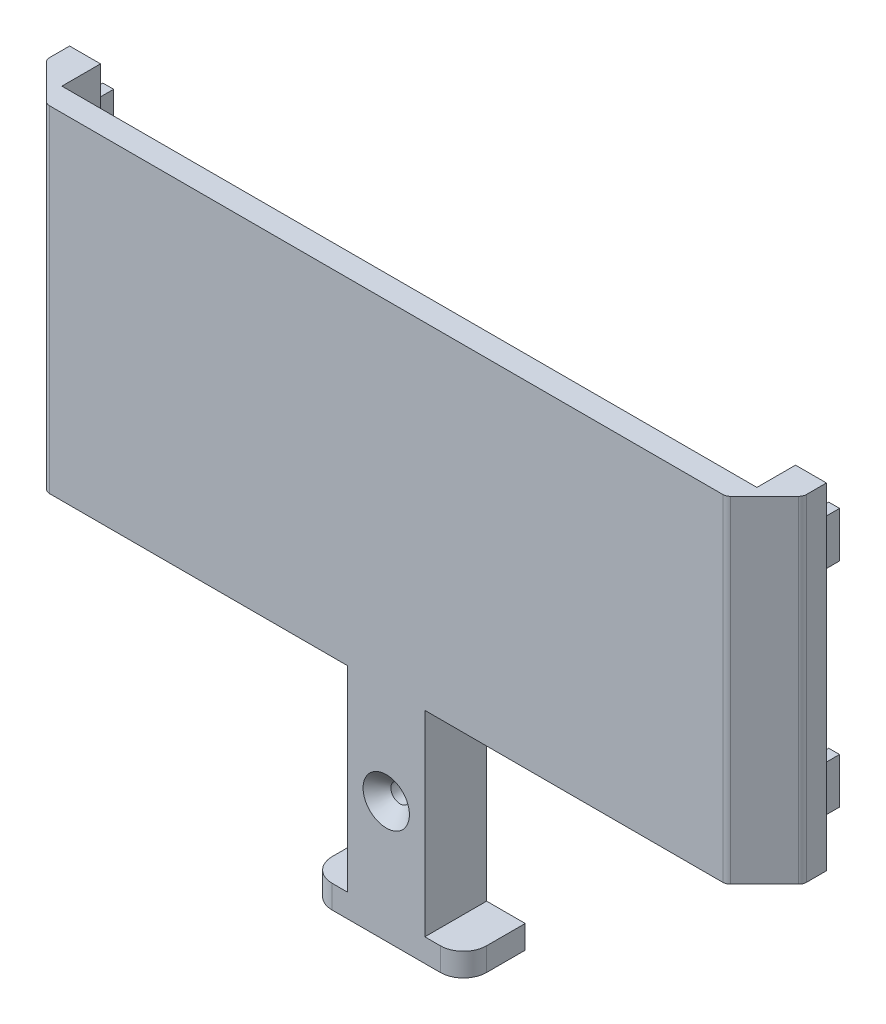
from build123d import *

# Parameters (mm, degrees)
SKETCH2_W                                       = 96
SKETCH2_H                                       = 38.5
BOSS_EXTRUDE1_DEPTH                             = 3
BOSS_EXTRUDE2_DEPTH                             = 45
BOSS_EXTRUDE2_DEPTH_BACK                        = 20
BOSS_EXTRUDE3_DEPTH                             = 20
BOSS_EXTRUDE3_DEPTH_BACK                        = 45
SKETCH5_W                                       = 8
SKETCH5_H                                       = 5
BOSS_EXTRUDE4_DEPTH                             = 96
SKETCH6_W                                       = 3
SKETCH6_H                                       = 5
BOSS_EXTRUDE5_DEPTH                             = 38.5
SKETCH7_R                                       = 7.5
SKETCH7_R_2                                     = 3.5
CUT_EXTRUDE2_DEPTH                              = 2
MOVE_FACE1_BY                                   = 1
MOVE_FACE2_BY                                   = 1
SKETCH8_W                                       = 1.4
SKETCH8_H                                       = 5.9
BOSS_EXTRUDE6_DEPTH                             = 3
SKETCH9_W                                       = 10
SKETCH9_H                                       = 8
BOSS_EXTRUDE7_DEPTH                             = 25.4
SKETCH11_W                                      = 8
SKETCH11_H                                      = 3
BOSS_EXTRUDE8_DEPTH                             = 10
CHAMFER1_SIZE                                   = 5
FILLET1_R                                       = 1
FILLET3_R                                       = 3
MOVE_FACE3_BY                                   = 2
CSK_FOR_M2_FLAT_HEAD_MACHINE_SCREW1_D           = 2.4
CSK_FOR_M2_FLAT_HEAD_MACHINE_SCREW1_CSINK_D     = 6
CSK_FOR_M2_FLAT_HEAD_MACHINE_SCREW1_CSINK_ANGLE = 90


with BuildPart() as part:
    # Sketch2 → Boss-Extrude1 (new body)
    with BuildSketch(Plane.XY):
        Rectangle(SKETCH2_W, SKETCH2_H)
    extrude(amount=BOSS_EXTRUDE1_DEPTH)

    # Sketch3 → Boss-Extrude2 (add, two sides: drawn at the far end of the back side and taken through both)
    with BuildSketch(Plane(origin=(0, 0, 0), x_dir=(0, 0, -1), z_dir=(1, 0, 0)).offset(-BOSS_EXTRUDE2_DEPTH_BACK)):
        with BuildLine():
            Line((0, -15.25), (1.75, -15.25))
            ThreePointArc((1.75, -15.25), (2.5, -14.5), (1.75, -13.75))
            Line((1.75, -13.75), (0, -13.75))
            Line((0, -13.75), (0, -15.25))
        make_face()
    extrude(amount=BOSS_EXTRUDE2_DEPTH + BOSS_EXTRUDE2_DEPTH_BACK)

    # Sketch3_3 → Boss-Extrude3 (add, two sides: drawn at the far end of the back side and taken through both)
    with BuildSketch(Plane(origin=(0, 0, 0), x_dir=(0, 0, -1), z_dir=(1, 0, 0)).offset(-BOSS_EXTRUDE3_DEPTH_BACK)):
        with BuildLine():
            Line((0, 13.75), (0, 15.25))
            Line((0, 15.25), (1.75, 15.25))
            ThreePointArc((1.75, 15.25), (2.5, 14.5), (1.75, 13.75))
            Line((1.75, 13.75), (0, 13.75))
        make_face()
    extrude(amount=BOSS_EXTRUDE3_DEPTH + BOSS_EXTRUDE3_DEPTH_BACK)

    # Cut-Extrude1 cone 1 section (through the dimple's axis) → Cut-Extrude1 (revolve, cut)
    with BuildSketch(Plane.YZ):
        Polygon((0, 0), (1.375, 0), (0, 1.375), align=None)
    revolve(axis=Axis((0, 0, 0), (0, 0, 1)), mode=Mode.SUBTRACT)

    # Sketch5 → Boss-Extrude4 (add, through all)
    with BuildSketch(Plane.ZY.offset(48)):
        with Locations((-1, -21.75)):
            Rectangle(SKETCH5_W, SKETCH5_H)
    extrude(amount=-BOSS_EXTRUDE4_DEPTH)

    # Sketch6 → Boss-Extrude5 (add, through all)
    with BuildSketch(Plane(origin=(0, -19.25, 0), x_dir=(1, 0, 0), z_dir=(0, 1, 0))):
        with Locations((-46.5, 2.5)):
            Rectangle(SKETCH6_W, SKETCH6_H)
        with Locations((46.5, 2.5)):
            Rectangle(SKETCH6_W, SKETCH6_H)
    extrude(amount=BOSS_EXTRUDE5_DEPTH)

    # Sketch7 → Cut-Extrude2 (cut)
    with BuildSketch(Plane(origin=(0, 0, 0), x_dir=(-1, 0, 0), z_dir=(0, 0, -1))):
        Circle(SKETCH7_R)
        Circle(SKETCH7_R_2, mode=Mode.SUBTRACT)
    extrude(amount=-CUT_EXTRUDE2_DEPTH, mode=Mode.SUBTRACT)

    # Move Face1: a face moved outward by 1.0
    extrude(part.faces().sort_by_distance((-48, -2.5, -1))[0], amount=MOVE_FACE1_BY, dir=(-1, 0, 0))

    # Move Face2: a face moved outward by 1.0
    extrude(part.faces().sort_by_distance((48, -2.5, -1))[0], amount=MOVE_FACE2_BY, dir=(1, 0, 0))

    # Sketch8 → Boss-Extrude6 (add)
    with BuildSketch(Plane(origin=(0, 0, -5), x_dir=(-1, 0, 0), z_dir=(0, 0, -1))):
        with Locations((-47, 11.3)):
            Rectangle(SKETCH8_W, SKETCH8_H)
        with Locations((-47, -16.3)):
            Rectangle(SKETCH8_W, SKETCH8_H)
        with Locations((47, 11.3)):
            Rectangle(SKETCH8_W, SKETCH8_H)
        with Locations((47, -16.3)):
            Rectangle(SKETCH8_W, SKETCH8_H)
    extrude(amount=BOSS_EXTRUDE6_DEPTH)

    # Sketch9 → Boss-Extrude7 (add)
    with BuildSketch(Plane.XZ.offset(24.25)):
        with Locations((0, -1)):
            Rectangle(SKETCH9_W, SKETCH9_H)
    extrude(amount=BOSS_EXTRUDE7_DEPTH)

    # Sketch11 → Boss-Extrude8 (add, symmetric)
    with BuildSketch(Plane(origin=(0, 0, 0), x_dir=(0, 0, -1), z_dir=(1, 0, 0))):
        with Locations((1, -51.15)):
            Rectangle(SKETCH11_W, SKETCH11_H)
    extrude(amount=BOSS_EXTRUDE8_DEPTH, both=True)

    # Chamfer1
    chamfer1_edges = [part.edges().sort_by_distance(p)[0] for p in [
        (49, -2.5, 3),
        (-49, -2.5, 3),
    ]]
    chamfer(chamfer1_edges, length=CHAMFER1_SIZE)

    # Fillet1
    fillet1_edges = [part.edges().sort_by_distance(p)[0] for p in [
        (44, -2.5, 3),
        (-44, -2.5, 3),
        (-49, -2.5, -2),
        (49, -2.5, -2),
    ]]
    fillet(fillet1_edges, radius=FILLET1_R)

    # Fillet3
    fillet3_edges = [part.edges().sort_by_distance(p)[0] for p in [
        (-10, -51.15, 3),
        (10, -51.15, 3),
    ]]
    fillet(fillet3_edges, radius=FILLET3_R)

    # Move Face3: a face moved inward by 2.0
    extrude(part.faces().sort_by_distance((0, -19.25, -2.5))[0], amount=MOVE_FACE3_BY, dir=(0, -1, 0), mode=Mode.SUBTRACT)

    # CSK for M2 Flat Head Machine Screw1 (through all)
    with Locations(Plane.XY.offset(3)):
        with Locations((0, -36.95)):
            CounterSinkHole(CSK_FOR_M2_FLAT_HEAD_MACHINE_SCREW1_D / 2, CSK_FOR_M2_FLAT_HEAD_MACHINE_SCREW1_CSINK_D / 2, counter_sink_angle=CSK_FOR_M2_FLAT_HEAD_MACHINE_SCREW1_CSINK_ANGLE)


solid = part.part
